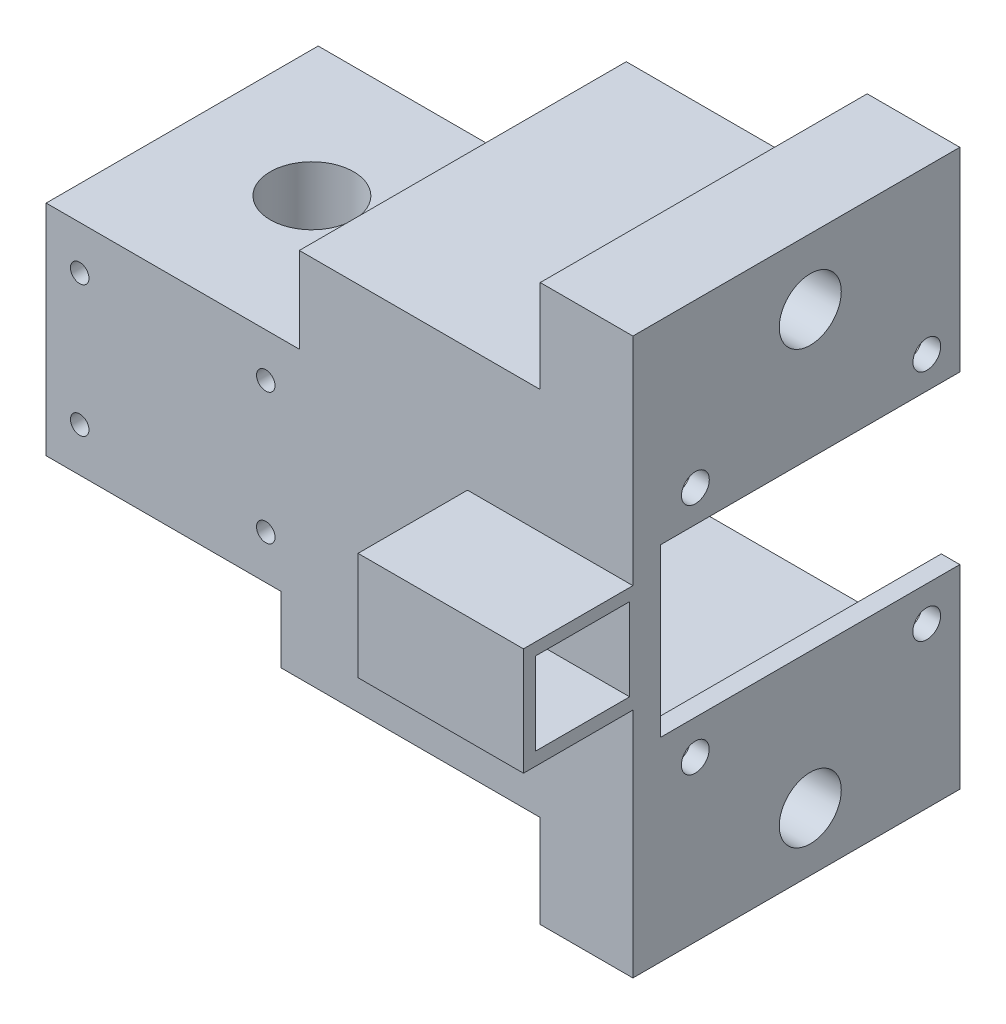
from build123d import *

# Parameters (mm, degrees)
SKETCH1_W            = 34.7
SKETCH1_H            = 30
BOSS_EXTRUDE1_DEPTH  = 37.282
SKETCH4_R            = 5.715
CUT_EXTRUDE1_DEPTH   = 31
SKETCH8_W            = 3.81
SKETCH8_H            = 50.8
BOSS_EXTRUDE6_DEPTH  = 45.72
BOSS_EXTRUDE7_DEPTH  = 41.000001
CUT_EXTRUDE2_REACH   = 82.42
SKETCH10_R           = 1.905
SKETCH11_W           = 12.7
SKETCH11_H           = 44.810000611
BOSS_EXTRUDE8_DEPTH  = 12.7
SKETCH12_W           = 12.7
SKETCH12_H           = 44.810000611
BOSS_EXTRUDE9_DEPTH  = 12.7
SKETCH13_R           = 4.25
CUT_EXTRUDE3_DEPTH   = 6.35
SKETCH17_W           = 3.43592392
SKETCH17_H           = 45.72
BOSS_EXTRUDE12_DEPTH = 33.472
SKETCH16_W           = 2.5
SKETCH16_H           = 37.282
BOSS_EXTRUDE11_DEPTH = 9.076061
SKETCH21_W           = 17.974491303
SKETCH21_H           = 23.94
BOSS_EXTRUDE13_DEPTH = 16
SKETCH22_W           = 13.379509134
SKETCH22_H           = 6.922502695
CUT_EXTRUDE4_DEPTH   = 45.810000611
SKETCH23_W           = 13.335762063
SKETCH23_H           = 11.735762062
CUT_EXTRUDE5_DEPTH   = 21.47692
SKETCH24_W           = 22.672584076
SKETCH24_H           = 14.765845737
BOSS_EXTRUDE14_DEPTH = 15
SKETCH25_W           = 12.9
SKETCH25_H           = 11.3
CUT_EXTRUDE6_DEPTH   = 22.672584
SKETCH5_R            = 1.375
CUT_EXTRUDE7_DEPTH   = 10
SKETCH6_R            = 1.27
CUT_EXTRUDE8_DEPTH   = 53.282
SKETCH27_W           = 17.974491303
SKETCH27_H           = 14.491353785
BOSS_EXTRUDE15_DEPTH = 2


with BuildPart() as part:
    # Sketch1 → Boss-Extrude1 (new body)
    with BuildSketch(Plane(origin=(0, 0, -264.675), x_dir=(-1, 0, 0), z_dir=(0, 0, -1))):
        with Locations((-46.026450848, -396.896376681)):
            Rectangle(SKETCH1_W, SKETCH1_H)
    extrude(amount=BOSS_EXTRUDE1_DEPTH)

    # Sketch4 → Cut-Extrude1 (cut, through all)
    with BuildSketch(Plane(origin=(0, -381.896376681, 0), x_dir=(1, 0, 0), z_dir=(0, 1, 0))):
        with Locations((46.026450848, 283.749893694)):
            Circle(SKETCH4_R)
    extrude(amount=-CUT_EXTRUDE1_DEPTH, mode=Mode.SUBTRACT)

    # Sketch8 → Boss-Extrude6 (add)
    with BuildSketch(Plane(origin=(63.376450848, 0, 0), x_dir=(0, 0, -1), z_dir=(1, 0, 0))):
        with Locations((266.58, -395.572437442)):
            Rectangle(SKETCH8_W, SKETCH8_H)
    extrude(amount=BOSS_EXTRUDE6_DEPTH)

    # Sketch9 → Boss-Extrude7 (add)
    with BuildSketch(Plane(origin=(0, 0, -268.485), x_dir=(-1, 0, 0), z_dir=(0, 0, -1))):
        Polygon((-109.096450848, -370.172437442), (-63.376450848, -370.172437442), (-63.376450848, -372.712437442), (-106.556450848, -372.712437442), (-106.556450848, -384.142437442), (-109.096450848, -384.142437442), (-109.096450848, -372.712437442), align=None)
        Polygon((-109.096450848, -420.972437442), (-63.376450848, -420.972437442), (-63.376450848, -418.432437442), (-106.556450848, -418.432437442), (-106.556450848, -407.002437442), (-109.096450848, -407.002437442), (-109.096450848, -418.432437442), align=None)
    extrude(amount=BOSS_EXTRUDE7_DEPTH)

    # Sketch10 → Cut-Extrude2 (cut, up to next)
    with BuildSketch(Plane(origin=(109.096450848, 0, 0), x_dir=(0, 0, -1), z_dir=(1, 0, 0)), mode=Mode.PRIVATE) as cut_extrude2_sk1:
        with Locations((304.963451053, -379.773986799)):
            Circle(SKETCH10_R)
    cut_extrude2_tool1 = extrude(cut_extrude2_sk1.sketch, amount=-CUT_EXTRUDE2_REACH, mode=Mode.PRIVATE) & part.part
    add(cut_extrude2_tool1.solids().sort_by_distance((109.096451, -379.773987, -304.963451))[0], mode=Mode.SUBTRACT)
    # Sketch10 → Cut-Extrude2 (cut, up to next)
    with BuildSketch(Plane(origin=(109.096450848, 0, 0), x_dir=(0, 0, -1), z_dir=(1, 0, 0)), mode=Mode.PRIVATE) as cut_extrude2_sk2:
        with Locations((304.941901697, -411.752437852)):
            Circle(SKETCH10_R)
    cut_extrude2_tool2 = extrude(cut_extrude2_sk2.sketch, amount=-CUT_EXTRUDE2_REACH, mode=Mode.PRIVATE) & part.part
    add(cut_extrude2_tool2.solids().sort_by_distance((109.096451, -411.752438, -304.941902))[0], mode=Mode.SUBTRACT)
    # Sketch10 → Cut-Extrude2 (cut, up to next)
    with BuildSketch(Plane(origin=(109.096450848, 0, 0), x_dir=(0, 0, -1), z_dir=(1, 0, 0)), mode=Mode.PRIVATE) as cut_extrude2_sk3:
        with Locations((273.239000003, -379.752437442)):
            Circle(SKETCH10_R)
    cut_extrude2_tool3 = extrude(cut_extrude2_sk3.sketch, amount=-CUT_EXTRUDE2_REACH, mode=Mode.PRIVATE) & part.part
    add(cut_extrude2_tool3.solids().sort_by_distance((109.096451, -379.752437, -273.239))[0], mode=Mode.SUBTRACT)
    # Sketch10 → Cut-Extrude2 (cut, up to next)
    with BuildSketch(Plane(origin=(109.096450848, 0, 0), x_dir=(0, 0, -1), z_dir=(1, 0, 0)), mode=Mode.PRIVATE) as cut_extrude2_sk4:
        with Locations((273.221901697, -411.730888495)):
            Circle(SKETCH10_R)
    cut_extrude2_tool4 = extrude(cut_extrude2_sk4.sketch, amount=-CUT_EXTRUDE2_REACH, mode=Mode.PRIVATE) & part.part
    add(cut_extrude2_tool4.solids().sort_by_distance((109.096451, -411.730888, -273.221902))[0], mode=Mode.SUBTRACT)

    # Sketch11 → Boss-Extrude8 (add)
    with BuildSketch(Plane(origin=(0, -370.172437442, 0), x_dir=(1, 0, 0), z_dir=(0, 1, 0))):
        with Locations((102.746450848, 287.080000305)):
            Rectangle(SKETCH11_W, SKETCH11_H)
    extrude(amount=BOSS_EXTRUDE8_DEPTH)

    # Sketch12 → Boss-Extrude9 (add)
    with BuildSketch(Plane.XZ.offset(420.972437442)):
        with Locations((102.746450848, -287.080000305)):
            Rectangle(SKETCH12_W, SKETCH12_H)
    extrude(amount=BOSS_EXTRUDE9_DEPTH)

    # Sketch13 → Cut-Extrude3 (cut)
    with BuildSketch(Plane(origin=(109.096450848, 0, 0), x_dir=(0, 0, -1), z_dir=(1, 0, 0))):
        with Locations((288.985000522, -366.472437442)):
            Circle(SKETCH13_R)
        with Locations((288.985000522, -425.654437442)):
            Circle(SKETCH13_R)
    extrude(amount=-CUT_EXTRUDE3_DEPTH, mode=Mode.SUBTRACT)

    # Sketch17 → Boss-Extrude12 (add)
    with BuildSketch(Plane(origin=(0, 0, -268.485), x_dir=(-1, 0, 0), z_dir=(0, 0, -1))):
        with Locations((-65.094412808, -395.572437442)):
            Rectangle(SKETCH17_W, SKETCH17_H)
    extrude(amount=BOSS_EXTRUDE12_DEPTH)

    # Sketch16 → Boss-Extrude11 (add)
    with BuildSketch(Plane.XZ.offset(411.896376681)):
        with Locations((62.126450848, -283.316)):
            Rectangle(SKETCH16_W, SKETCH16_H)
    extrude(amount=BOSS_EXTRUDE11_DEPTH)

    # Sketch21 → Boss-Extrude13 (add)
    with BuildSketch(Plane(origin=(0, 0, -309.485000611), x_dir=(-1, 0, 0), z_dir=(0, 0, -1))):
        with Locations((-67.875046239, -432.942437442)):
            Rectangle(SKETCH21_W, SKETCH21_H)
    extrude(amount=-BOSS_EXTRUDE13_DEPTH)

    # Sketch22 → Cut-Extrude4 (cut, through all)
    with BuildSketch(Plane(origin=(0, 0, -309.485000611), x_dir=(-1, 0, 0), z_dir=(0, 0, -1))):
        with Locations((-67.562480009, -426.896769229)):
            Rectangle(SKETCH22_W, SKETCH22_H)
    extrude(amount=-CUT_EXTRUDE4_DEPTH, mode=Mode.SUBTRACT)

    # Sketch23 → Cut-Extrude5 (cut)
    with BuildSketch(Plane.XZ.offset(444.912437442)):
        with Locations((67.776450849, -303.385000611)):
            Rectangle(SKETCH23_W, SKETCH23_H)
    extrude(amount=-CUT_EXTRUDE5_DEPTH, mode=Mode.SUBTRACT)

    # Sketch24 → Boss-Extrude14 (add)
    with BuildSketch(Plane.XY.offset(-264.675)):
        with Locations((97.76015881, -394.484447642)):
            Rectangle(SKETCH24_W, SKETCH24_H)
    extrude(amount=BOSS_EXTRUDE14_DEPTH)

    # Sketch25 → Cut-Extrude6 (cut)
    with BuildSketch(Plane(origin=(109.096450848, 0, 0), x_dir=(0, 0, -1), z_dir=(1, 0, 0))):
        with Locations((257.775, -394.422437442)):
            Rectangle(SKETCH25_W, SKETCH25_H)
    extrude(amount=-CUT_EXTRUDE6_DEPTH, mode=Mode.SUBTRACT)

    # Sketch5 → Cut-Extrude7 (cut)
    with BuildSketch(Plane.XZ.offset(411.896376681)):
        with Locations((46.453266338, -275.535975412)):
            Circle(SKETCH5_R)
        with Locations((54.24036913, -284.176709184)):
            Circle(SKETCH5_R)
        with Locations((45.599635358, -291.963811975)):
            Circle(SKETCH5_R)
        with Locations((37.812532567, -283.323078204)):
            Circle(SKETCH5_R)
    extrude(amount=-CUT_EXTRUDE7_DEPTH, mode=Mode.SUBTRACT)

    # Sketch6 → Cut-Extrude8 (cut, through all)
    with BuildSketch(Plane(origin=(0, 0, -301.957), x_dir=(-1, 0, 0), z_dir=(0, 0, -1))):
        with Locations((-58.776450848, -387.896376681)):
            Circle(SKETCH6_R)
        with Locations((-33.276450848, -387.896376681)):
            Circle(SKETCH6_R)
        with Locations((-33.276450848, -405.896376681)):
            Circle(SKETCH6_R)
        with Locations((-58.776450848, -405.896376681)):
            Circle(SKETCH6_R)
    extrude(amount=-CUT_EXTRUDE8_DEPTH, mode=Mode.SUBTRACT)

    # Sketch27 → Boss-Extrude15 (add)
    with BuildSketch(Plane(origin=(0, 0, -309.485000611), x_dir=(-1, 0, 0), z_dir=(0, 0, -1))):
        with Locations((-67.875046239, -437.66676055)):
            Rectangle(SKETCH27_W, SKETCH27_H)
    extrude(amount=BOSS_EXTRUDE15_DEPTH)


solid = part.part
